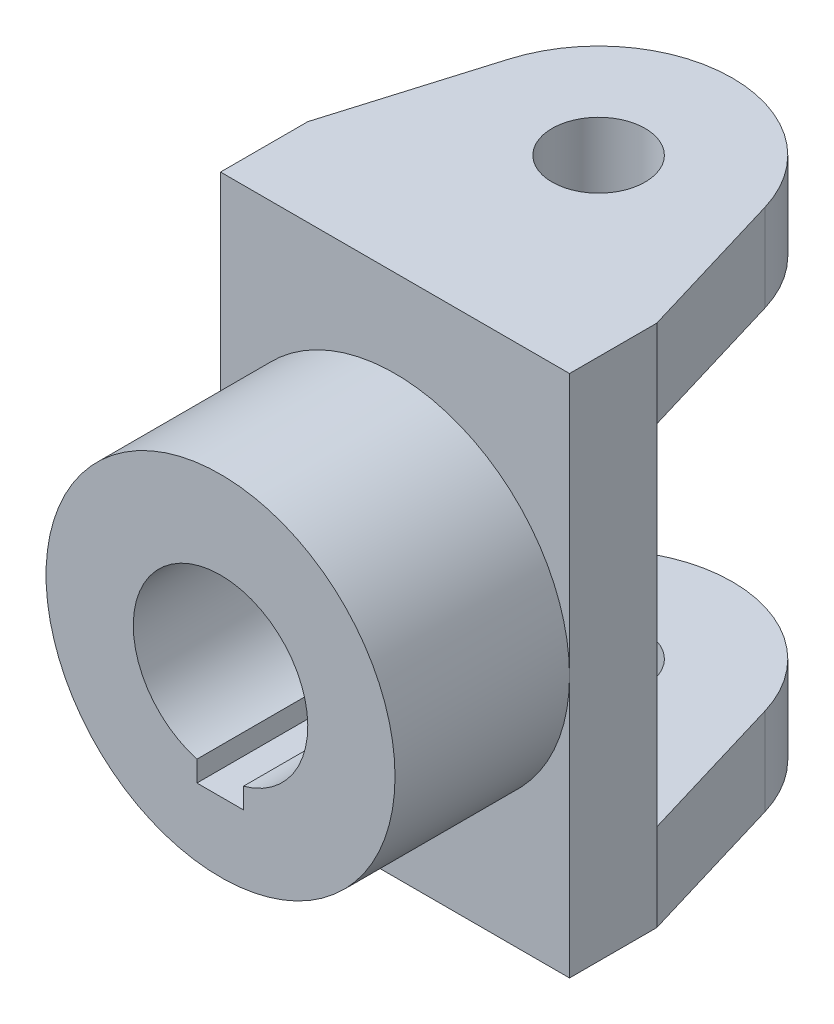
from build123d import *

# Parameters (mm, degrees)
SKETCH1_W           = 60
SKETCH1_H           = 90
BOSS_EXTRUDE1_DEPTH = 15
SKETCH2_R           = 30
BOSS_EXTRUDE2_DEPTH = 30
SKETCH3_R           = 8
BOSS_EXTRUDE3_DEPTH = 15


with BuildPart() as part:
    # Sketch1 → Boss-Extrude1 (new body)
    with BuildSketch(Plane.XY):
        Rectangle(SKETCH1_W, SKETCH1_H)
    extrude(amount=BOSS_EXTRUDE1_DEPTH)

    # Sketch2 → Boss-Extrude2 (add)
    with BuildSketch(Plane.XY.offset(15)):
        Circle(SKETCH2_R)
        with BuildLine():
            Line((-4.058122732, -14.440624637), (-4.058122732, -17.999887391))
            Line((-4.058122732, -17.999887391), (3.941877268, -17.999887391))
            Line((3.941877268, -17.999887391), (3.941877268, -14.472788384))
            ThreePointArc((3.941877268, -14.472788384), (0.060306539, 14.99987877), (-4.058122732, -14.440624637))
        make_face(mode=Mode.SUBTRACT)
    extrude(amount=BOSS_EXTRUDE2_DEPTH)

    # Sketch3 → Boss-Extrude3 (add)
    with BuildSketch(Plane(origin=(0, 45, 0), x_dir=(1, 0, 0), z_dir=(0, 1, 0))):
        with BuildLine():
            Line((-30, 0), (30, 0))
            Line((30, 0), (22.03289839, 26.599347585))
            ThreePointArc((22.03289839, 26.599347585), (0, 43), (-22.03289839, 26.599347585))
            Line((-22.03289839, 26.599347585), (-30, 0))
        make_face()
        with Locations((0, 20)):
            Circle(SKETCH3_R, mode=Mode.SUBTRACT)
    boss_extrude3 = extrude(amount=-BOSS_EXTRUDE3_DEPTH)

    # Mirror1: Boss-Extrude3 across plane
    add(boss_extrude3.mirror(Plane.ZX))


solid = part.part
